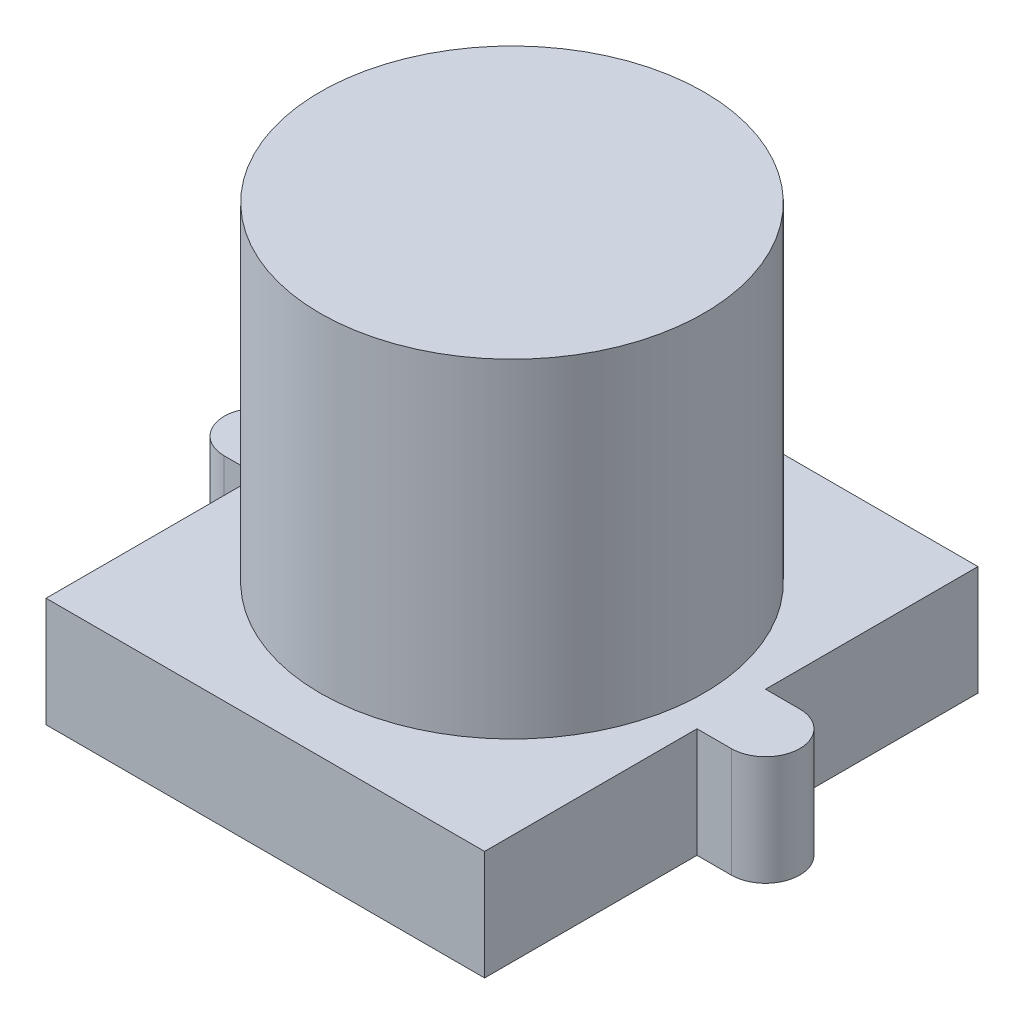
from build123d import *

# Parameters (mm, degrees)
BOSS_EXTRUDE1_DEPTH = 4
SKETCH2_R           = 7
BOSS_EXTRUDE2_DEPTH = 12


with BuildPart() as part:
    # Sketch1 → Boss-Extrude1 (new body)
    with BuildSketch(Plane(origin=(0, 0, 0), x_dir=(1, 0, 0), z_dir=(0, 1, 0))):
        with BuildLine():
            Line((0, 0), (16, 0))
            Line((16, 0), (16, 7.75))
            Line((16, 7.75), (17.25, 7.75))
            ThreePointArc((17.25, 7.75), (18.5, 9), (17.25, 10.25))
            Line((17.25, 10.25), (16, 10.25))
            Line((16, 10.25), (16, 18))
            Line((16, 18), (0, 18))
            Line((0, 18), (0, 10.25))
            Line((0, 10.25), (-1.25, 10.25))
            ThreePointArc((-1.25, 10.25), (-2.5, 9), (-1.25, 7.75))
            Line((-1.25, 7.75), (0, 7.75))
            Line((0, 7.75), (0, 0))
        make_face()
    extrude(amount=BOSS_EXTRUDE1_DEPTH)

    # Sketch2 → Boss-Extrude2 (add)
    with BuildSketch(Plane(origin=(0, 4, 0), x_dir=(1, 0, 0), z_dir=(0, 1, 0))):
        with Locations((8, 9)):
            Circle(SKETCH2_R)
    extrude(amount=BOSS_EXTRUDE2_DEPTH)


solid = part.part
